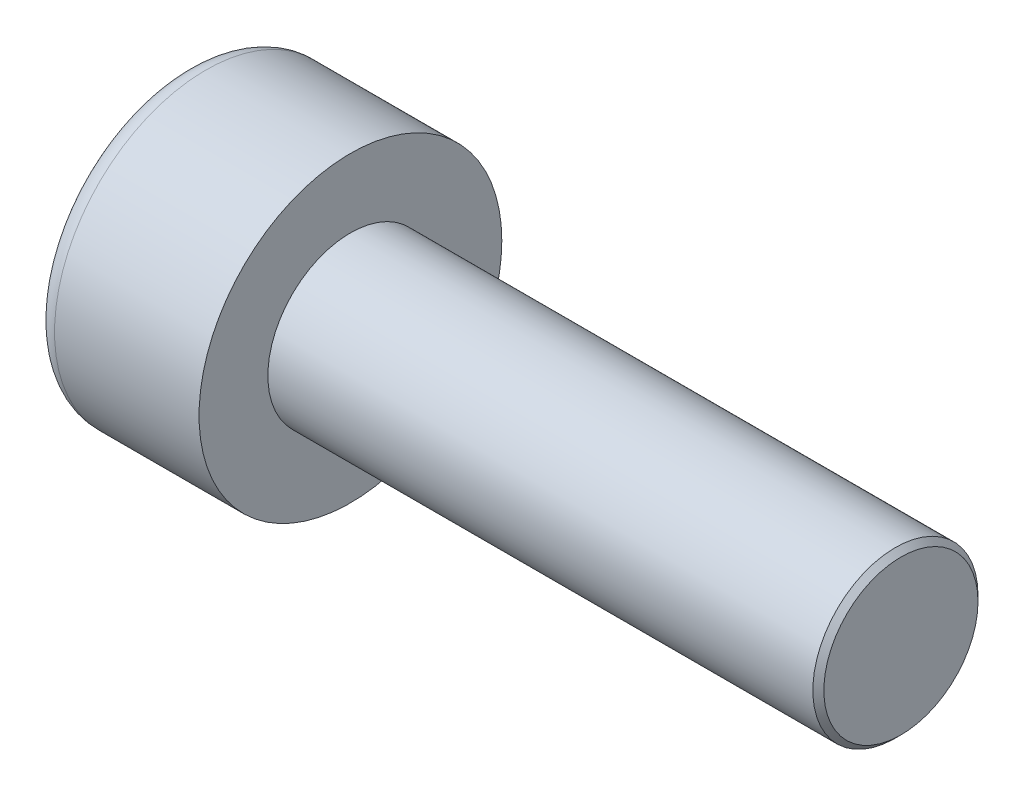
from build123d import *

# Parameters (mm, degrees)
SKETCH1_R           = 2.75
BASEHEAD_DEPTH      = 3
SKETCH2_R           = 1.5
BASEBODY_DEPTH      = 10
HEXAGONSOCKET_DEPTH = 1.3
TOPFILLET_R         = 0.375
CHAMFER1_SIZE       = 0.1


with BuildPart() as part:
    # Sketch1 → BaseHead (new body)
    with BuildSketch(Plane(origin=(0, 0, 0), x_dir=(0, 0, -1), z_dir=(1, 0, 0))):
        Circle(SKETCH1_R)
    extrude(amount=BASEHEAD_DEPTH)

    # Sketch2 → BaseBody (add)
    with BuildSketch(Plane(origin=(3, 0, 0), x_dir=(0, 0, -1), z_dir=(1, 0, 0))):
        Circle(SKETCH2_R)
    extrude(amount=BASEBODY_DEPTH)

    # Sketch3 → HexagonSocket (cut)
    with BuildSketch(Plane(origin=(0, 0, 0), x_dir=(0, 0, -1), z_dir=(1, 0, 0))):
        Polygon((1.443375673, 0), (0.721687836, 1.25), (-0.721687836, 1.25), (-1.443375673, 0), (-0.721687836, -1.25), (0.721687836, -1.25), align=None)
    extrude(amount=HEXAGONSOCKET_DEPTH, mode=Mode.SUBTRACT)

    # Sketch4 → Cut-Revolve1 (revolve, cut)
    with BuildSketch(Plane(origin=(-4.19613823, 0.75, 0), x_dir=(-1, 0, 0), z_dir=(0, 0, 1))):
        Polygon((-5.49613823, 2), (-6.217826066, 0.75), (-5.49613823, 0.75), align=None)
    revolve(axis=Axis((0.838992387, 0, 0), (-1, 0, 0)), mode=Mode.SUBTRACT)

    # TopFillet
    topfillet_edges = [part.edges().sort_by_distance(p)[0] for p in [
        (0, 0, 2.75),
    ]]
    fillet(topfillet_edges, radius=TOPFILLET_R)

    # Chamfer1
    chamfer1_edges = [part.edges().sort_by_distance(p)[0] for p in [
        (13, 0, 1.5),
    ]]
    chamfer(chamfer1_edges, length=CHAMFER1_SIZE)


solid = part.part
